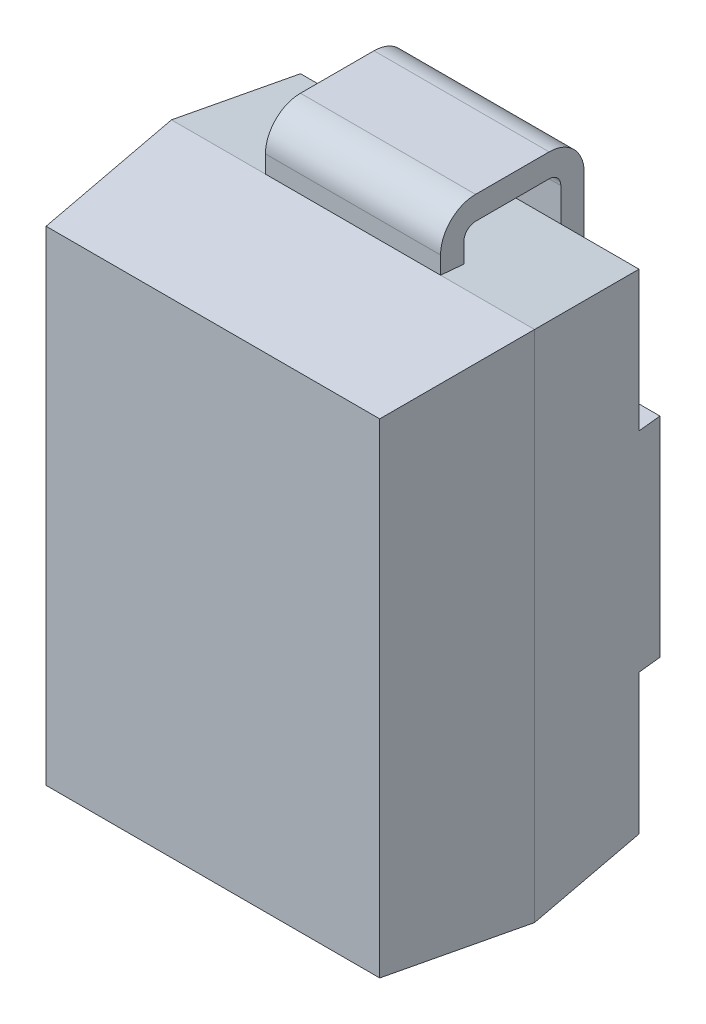
from build123d import *

# Parameters (mm, degrees)
SZKIC1_W                        = 3.11
SZKIC1_H                        = 4.4
DODANIE_WYCI_GNI_CIE1_DEPTH     = 1.2
DODANIE_WYCI_GNI_CIE1_TAPER     = 6
WYTNIJ_WYCI_GNI_CIE1_DEPTH      = 2.555
WYTNIJ_WYCI_GNI_CIE1_DEPTH_BACK = 2.555
DODANIE_WYCI_GNI_CIE2_DEPTH     = 0.75
DODANIE_WYCI_GNI_CIE2_2_DEPTH   = 0.75


with BuildPart() as part:
    # Szkic1 → Dodanie-wyciągnięcie1 (new body)
    with BuildSketch(Plane.XY):
        Rectangle(SZKIC1_W, SZKIC1_H)
    extrude(amount=DODANIE_WYCI_GNI_CIE1_DEPTH, taper=DODANIE_WYCI_GNI_CIE1_TAPER)

    # Lustro1: part across plane


with BuildPart() as part_1:
    add(part.part)
    add(part.part.mirror(Plane(origin=(0, 0, 0), x_dir=(1, 0, 0), z_dir=(0, 0, -1))))

    # Szkic3 → Wytnij-wyciągnięcie1 (cut, two sides)
    with BuildSketch(Plane(origin=(0, 0, 0), x_dir=(0, 0, -1), z_dir=(1, 0, 0))) as wytnij_wyci_gni_cie1_sk:
        Polygon((1.2, -0.895), (1, -0.895), (1, -2.564937585), (1.280608908, -2.564937585), align=None)
        Polygon((1, 0.895), (1.2, 0.895), (1.494406122, 2.600403108), (1, 2.660266328), align=None)
    extrude(amount=WYTNIJ_WYCI_GNI_CIE1_DEPTH, mode=Mode.SUBTRACT)
    extrude(wytnij_wyci_gni_cie1_sk.sketch, amount=-WYTNIJ_WYCI_GNI_CIE1_DEPTH_BACK, mode=Mode.SUBTRACT)


with BuildPart() as body_2:
    # Szkic5 → Dodanie-wyciągnięcie2 (new body, symmetric)
    with BuildSketch(Plane(origin=(0, 0, 0), x_dir=(0, 0, -1), z_dir=(1, 0, 0))):
        with BuildLine():
            Line((0.2, -2.35), (0.2, -2.182502267))
            Line((0.2, -2.182502267), (0, -2.2))
            Line((0, -2.2), (0, -2.35))
            ThreePointArc((0, -2.35), (0.087867966, -2.562132034), (0.3, -2.65))
            Line((0.3, -2.65), (0.93, -2.65))
            ThreePointArc((0.93, -2.65), (1.142132034, -2.562132034), (1.23, -2.35))
            Line((1.23, -2.35), (1.23, -1.15))
            Line((1.23, -1.15), (1.03, -1.15))
            Line((1.03, -1.15), (1.03, -2.35))
            ThreePointArc((1.03, -2.35), (1.000710678, -2.420710678), (0.93, -2.45))
            Line((0.93, -2.45), (0.3, -2.45))
            ThreePointArc((0.3, -2.45), (0.229289322, -2.420710678), (0.2, -2.35))
        make_face()
    extrude(amount=DODANIE_WYCI_GNI_CIE2_DEPTH, both=True)


with BuildPart() as body_3:
    # Szkic5 → Dodanie-wyci_gni_cie2 2 (new body, symmetric)
    with BuildSketch(Plane(origin=(0, 0, 0), x_dir=(0, 0, -1), z_dir=(1, 0, 0))):
        with BuildLine():
            Line((0.93, 2.65), (0.3, 2.65))
            ThreePointArc((0.3, 2.65), (0.087867966, 2.562132034), (0, 2.35))
            Line((0, 2.35), (0, 2.2))
            Line((0, 2.2), (0.2, 2.182502267))
            Line((0.2, 2.182502267), (0.2, 2.35))
            ThreePointArc((0.2, 2.35), (0.229289322, 2.420710678), (0.3, 2.45))
            Line((0.3, 2.45), (0.93, 2.45))
            ThreePointArc((0.93, 2.45), (1.000710678, 2.420710678), (1.03, 2.35))
            Line((1.03, 2.35), (1.03, 1.15))
            Line((1.03, 1.15), (1.23, 1.15))
            Line((1.23, 1.15), (1.23, 2.35))
            ThreePointArc((1.23, 2.35), (1.142132034, 2.562132034), (0.93, 2.65))
        make_face()
    extrude(amount=DODANIE_WYCI_GNI_CIE2_2_DEPTH, both=True)


solid = Compound([part_1.part, body_2.part, body_3.part])
